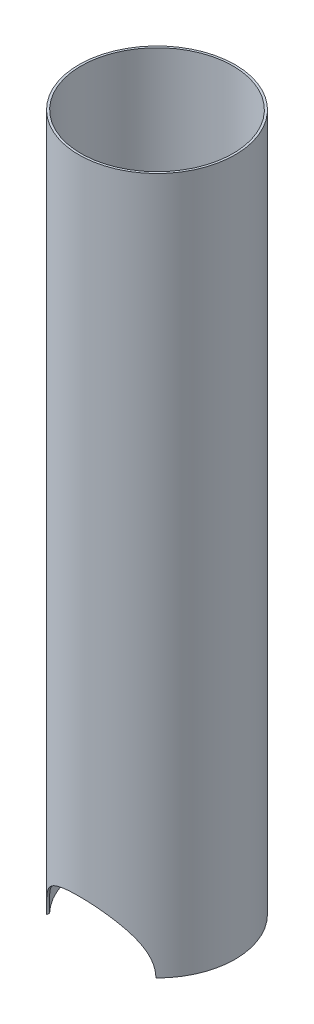
from build123d import *

# Parameters (mm, degrees)
SKETCH1_R                        = 57.15
SKETCH1_R_2                      = 55.5625
OEM_DEPTH                        = 457.2
OEM_DEPTH_BACK                   = 152.4
ENSR_BASEPLATE_CUTOUT_DEPTH      = 58.15
ENSR_BASEPLATE_CUTOUT_DEPTH_BACK = 58.15
SKETCH6_W                        = 114.3
SKETCH6_H                        = 100
TOO_LONG_DEPTH                   = 58.1500001
TOO_LONG_DEPTH_BACK              = 58.1500001
SKETCH7_R                        = 4.7625
SKETCH7_R_2                      = 3.175
CONDUIT_DEPTH                    = 300
CONDUIT_DEPTH_BACK               = 10
SKETCH3_R                        = 57.15
SKETCH3_R_2                      = 3.175
FLOOR_2_DEPTH                    = 1.5875


with BuildPart() as part:
    # Sketch1 → OEM (new body, two sides)
    with BuildSketch(Plane(origin=(0, 0, 0), x_dir=(1, 0, 0), z_dir=(0, 1, 0))) as oem_sk:
        Circle(SKETCH1_R)
        Circle(SKETCH1_R_2, mode=Mode.SUBTRACT)
    extrude(amount=OEM_DEPTH)
    extrude(oem_sk.sketch, amount=-OEM_DEPTH_BACK)

    # Sketch5 → eNSR baseplate cutout (cut, two sides)
    with BuildSketch(Plane.XY) as ensr_baseplate_cutout_sk:
        with BuildLine():
            Line((40, -1396.985408143), (40, -152.4))
            ThreePointArc((40, -152.4), (0, -112.4), (-40, -152.4))
            Line((-40, -152.4), (-40, -1396.985408143))
            Line((-40, -1396.985408143), (-40, -3886.156224429))
            Line((-40, -3886.156224429), (40, -3886.156224429))
            Line((40, -3886.156224429), (40, -1396.985408143))
        make_face()
    extrude(amount=ENSR_BASEPLATE_CUTOUT_DEPTH, mode=Mode.SUBTRACT)
    extrude(ensr_baseplate_cutout_sk.sketch, amount=-ENSR_BASEPLATE_CUTOUT_DEPTH_BACK, mode=Mode.SUBTRACT)

    # Sketch6 → too long (cut, two sides)
    with BuildSketch(Plane.XY) as too_long_sk:
        with Locations((0, 407.2)):
            Rectangle(SKETCH6_W, SKETCH6_H)
    extrude(amount=TOO_LONG_DEPTH, mode=Mode.SUBTRACT)
    extrude(too_long_sk.sketch, amount=-TOO_LONG_DEPTH_BACK, mode=Mode.SUBTRACT)

    # Sketch7 → conduit (add, two sides)
    with BuildSketch(Plane(origin=(0, -110, 0), x_dir=(1, 0, 0), z_dir=(0, 1, 0))) as conduit_sk:
        with Locations((52.3875, 0)):
            Circle(SKETCH7_R)
        with Locations((52.3875, 0)):
            Circle(SKETCH7_R_2, mode=Mode.SUBTRACT)
    extrude(amount=CONDUIT_DEPTH)
    extrude(conduit_sk.sketch, amount=-CONDUIT_DEPTH_BACK)

    # Sketch3 → floor 2 (add)
    with BuildSketch(Plane(origin=(0, -110, 0), x_dir=(1, 0, 0), z_dir=(0, 1, 0))):
        Circle(SKETCH3_R)
        with Locations((52.3875, 0)):
            Circle(SKETCH3_R_2, mode=Mode.SUBTRACT)
    extrude(amount=FLOOR_2_DEPTH)


solid = part.part
